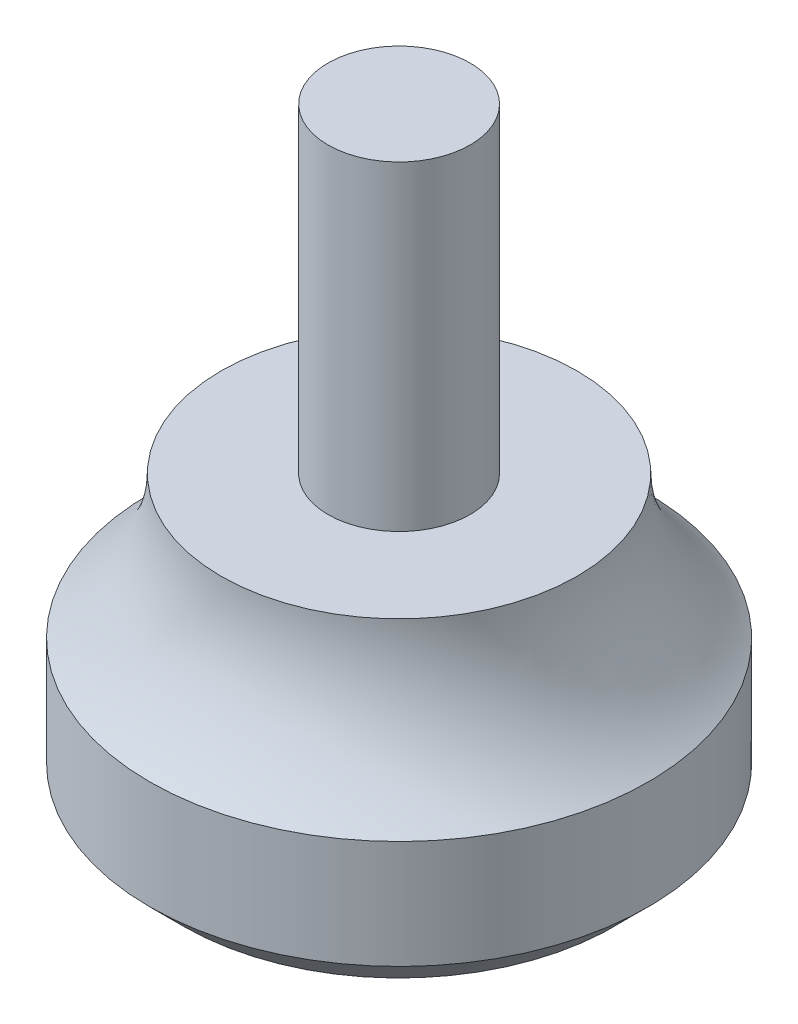
from build123d import *

# Parameters (mm, degrees)
CHAMFER1_SIZE = 1.524


with BuildPart() as part:
    # Sketch1 → Revolve1 (revolve)
    with BuildSketch(Plane.XY):
        with BuildLine():
            Line((0, 0), (0, 26.9748))
            Line((0, 26.9748), (3.16865, 26.9748))
            Line((3.16865, 26.9748), (3.16865, 12.7))
            Line((3.16865, 12.7), (7.9375, 12.7))
            ThreePointArc((7.9375, 12.7), (8.777939273, 9.148340087), (11.120996905, 6.35))
            Line((11.120996905, 6.35), (11.120996905, 0))
            Line((11.120996905, 0), (0, 0))
        make_face()
    revolve(axis=Axis((0, 0, 0), (0, -1, 0)))

    # Chamfer1
    chamfer1_edges = [part.edges().sort_by_distance(p)[0] for p in [
        (-11.120996905, 0, 0),
    ]]
    chamfer(chamfer1_edges, length=CHAMFER1_SIZE)


solid = part.part
